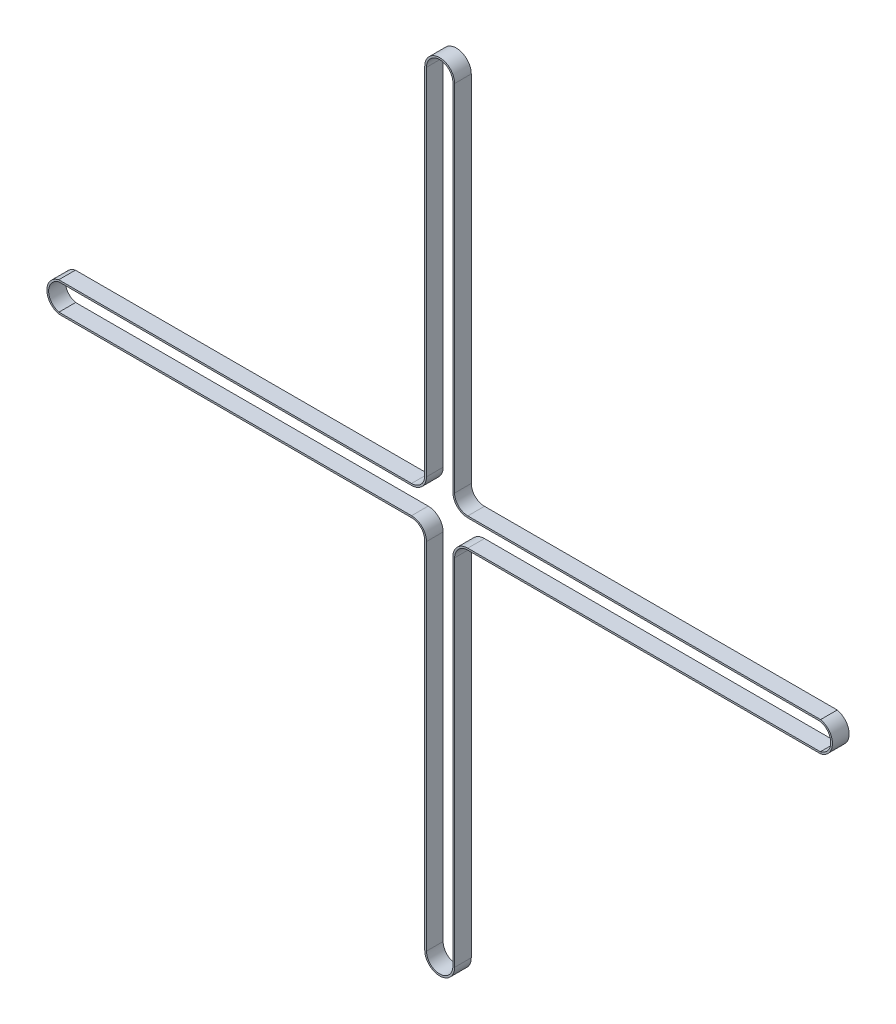
from build123d import *

# Parameters (mm, degrees)
EXTRUDE_1_DEPTH = 6


with BuildPart() as part:
    # 草图1 → 凸台-拉伸1 (new body)
    with BuildSketch(Plane.XY):
        with BuildLine():
            Line((-5.38, 7.694214332), (-5.38, -120.055785668))
            ThreePointArc((-5.38, -120.055785668), (-6.771242789, -123.414542878), (-10.13, -124.805785668))
            Line((-10.13, -124.805785668), (-137.202114628, -124.805785668))
            ThreePointArc((-137.202114628, -124.805785668), (-141.48, -130.152309812), (-137.202114628, -135.498833956))
            Line((-137.202114628, -135.498833956), (-10.13, -135.498833956))
            ThreePointArc((-10.13, -135.498833956), (-6.771242789, -136.890076745), (-5.38, -140.248833956))
            Line((-5.38, -140.248833956), (-5.38, -267.998833956))
            ThreePointArc((-5.38, -267.998833956), (0, -273.378833956), (5.38, -267.998833956))
            Line((5.38, -267.998833956), (5.38, -140.248833956))
            ThreePointArc((5.38, -140.248833956), (6.771242789, -136.890076745), (10.13, -135.498833956))
            Line((10.13, -135.498833956), (137.202114628, -135.498833956))
            ThreePointArc((137.202114628, -135.498833956), (141.48, -130.152309812), (137.202114628, -124.805785668))
            Line((137.202114628, -124.805785668), (10.13, -124.805785668))
            ThreePointArc((10.13, -124.805785668), (6.771242789, -123.414542878), (5.38, -120.055785668))
            Line((5.38, -120.055785668), (5.38, 7.694214332))
            ThreePointArc((5.38, 7.694214332), (0, 13.074214332), (-5.38, 7.694214332))
        make_face()
        with BuildLine():
            Line((-4.75, 7.694214332), (-4.75, -120.055785668))
            ThreePointArc((-4.75, -120.055785668), (-6.325765517, -123.860020151), (-10.13, -125.435785668))
            Line((-10.13, -125.435785668), (-137.13, -125.435785668))
            ThreePointArc((-137.13, -125.435785668), (-140.85, -130.152309812), (-137.13, -134.868833956))
            Line((-137.13, -134.868833956), (-10.13, -134.868833956))
            ThreePointArc((-10.13, -134.868833956), (-6.325765517, -136.444599473), (-4.75, -140.248833956))
            Line((-4.75, -140.248833956), (-4.75, -267.998833956))
            ThreePointArc((-4.75, -267.998833956), (0, -272.748833956), (4.75, -267.998833956))
            Line((4.75, -267.998833956), (4.75, -140.248833956))
            ThreePointArc((4.75, -140.248833956), (6.325765517, -136.444599473), (10.13, -134.868833956))
            Line((10.13, -134.868833956), (137.13, -134.868833956))
            ThreePointArc((137.13, -134.868833956), (140.85, -130.152309812), (137.13, -125.435785668))
            Line((137.13, -125.435785668), (10.13, -125.435785668))
            ThreePointArc((10.13, -125.435785668), (6.325765517, -123.860020151), (4.75, -120.055785668))
            Line((4.75, -120.055785668), (4.75, 7.694214332))
            ThreePointArc((4.75, 7.694214332), (0, 12.444214332), (-4.75, 7.694214332))
        make_face(mode=Mode.SUBTRACT)
    extrude(amount=EXTRUDE_1_DEPTH)


solid = part.part
